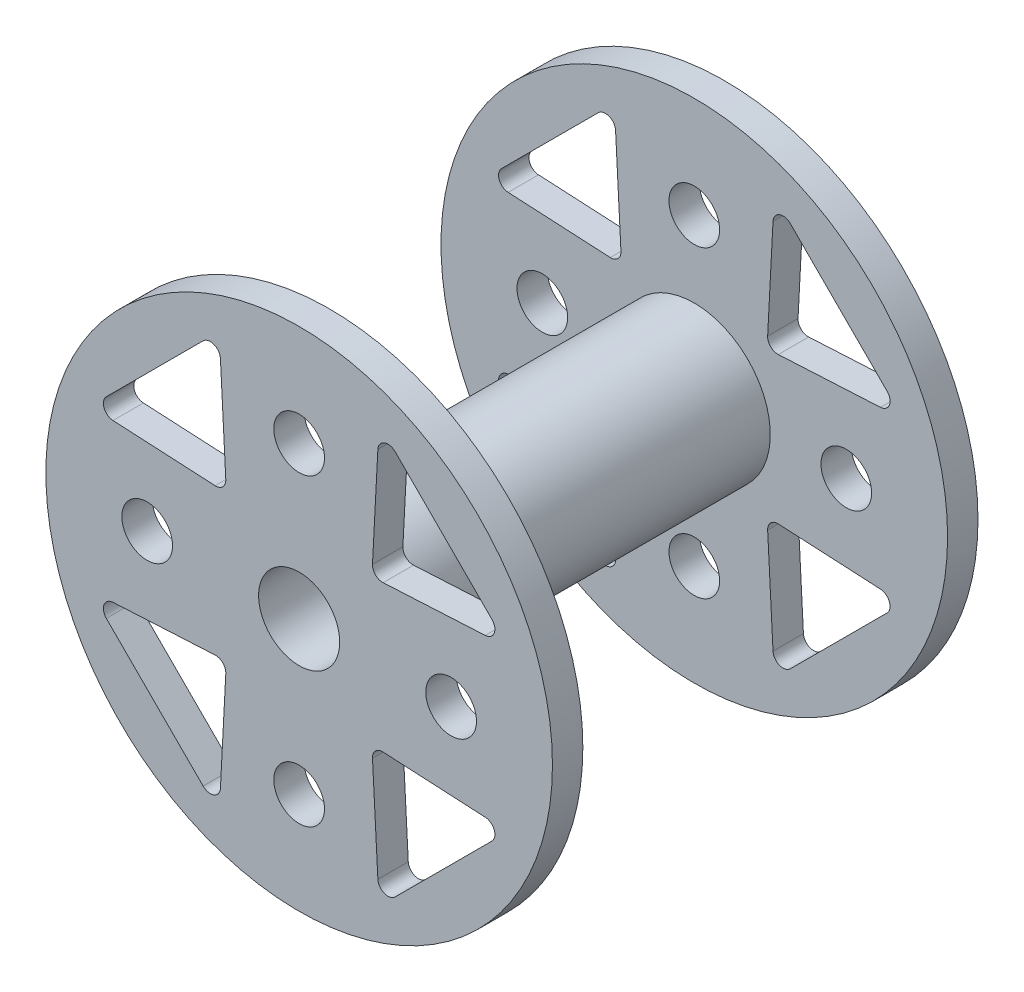
from build123d import *

# Parameters (mm, degrees)
CROQUIS1_R              = 7.5
CROQUIS1_R_2            = 4
SALIENTE_EXTRUIR1_DEPTH = 36
CROQUIS2_R              = 25
CROQUIS2_R_2            = 4
CROQUIS2_R_3            = 2.5
SALIENTE_EXTRUIR2_DEPTH = 3


with BuildPart() as part:
    # Croquis1 → Saliente-Extruir1 (new body)
    with BuildSketch(Plane.XY):
        Circle(CROQUIS1_R)
        Circle(CROQUIS1_R_2, mode=Mode.SUBTRACT)
    extrude(amount=SALIENTE_EXTRUIR1_DEPTH)

    # Croquis2 → Saliente-Extruir2 (add)
    with BuildSketch(Plane.XY.offset(36)):
        Circle(CROQUIS2_R)
        Circle(CROQUIS2_R_2, mode=Mode.SUBTRACT)
        with Locations((0, 15)):
            Circle(CROQUIS2_R_3, mode=Mode.SUBTRACT)
        with Locations((15, 0)):
            Circle(CROQUIS2_R_3, mode=Mode.SUBTRACT)
        with Locations((0, -15)):
            Circle(CROQUIS2_R_3, mode=Mode.SUBTRACT)
        with Locations((-15, 0)):
            Circle(CROQUIS2_R_3, mode=Mode.SUBTRACT)
        with BuildLine():
            Line((-19.027844597, 9.475344501), (-9.475344501, 19.027844597))
            ThreePointArc((-9.475344501, 19.027844597), (-8.409973952, 19.254358227), (-7.76961989, 18.373296649))
            Line((-7.76961989, 18.373296649), (-7.23892544, 8.290102103))
            ThreePointArc((-7.23892544, 8.290102103), (-7.530436489, 7.530436489), (-8.290102103, 7.23892544))
            Line((-8.290102103, 7.23892544), (-18.373296649, 7.76961989))
            ThreePointArc((-18.373296649, 7.76961989), (-19.254358227, 8.409973952), (-19.027844597, 9.475344501))
        make_face(mode=Mode.SUBTRACT)
        with BuildLine():
            Line((7.76961989, 18.373296649), (7.23892544, 8.290102103))
            ThreePointArc((7.23892544, 8.290102103), (7.530436489, 7.530436489), (8.290102103, 7.23892544))
            Line((8.290102103, 7.23892544), (18.373296649, 7.76961989))
            ThreePointArc((18.373296649, 7.76961989), (19.254358227, 8.409973952), (19.027844597, 9.475344501))
            Line((19.027844597, 9.475344501), (9.475344501, 19.027844597))
            ThreePointArc((9.475344501, 19.027844597), (8.409973952, 19.254358227), (7.76961989, 18.373296649))
        make_face(mode=Mode.SUBTRACT)
        with BuildLine():
            Line((18.373296649, -7.76961989), (8.290102103, -7.23892544))
            ThreePointArc((8.290102103, -7.23892544), (7.530436489, -7.530436489), (7.23892544, -8.290102103))
            Line((7.23892544, -8.290102103), (7.76961989, -18.373296649))
            ThreePointArc((7.76961989, -18.373296649), (8.409973952, -19.254358227), (9.475344501, -19.027844597))
            Line((9.475344501, -19.027844597), (19.027844597, -9.475344501))
            ThreePointArc((19.027844597, -9.475344501), (19.254358227, -8.409973952), (18.373296649, -7.76961989))
        make_face(mode=Mode.SUBTRACT)
        with BuildLine():
            Line((-7.76961989, -18.373296649), (-7.23892544, -8.290102103))
            ThreePointArc((-7.23892544, -8.290102103), (-7.530436489, -7.530436489), (-8.290102103, -7.23892544))
            Line((-8.290102103, -7.23892544), (-18.373296649, -7.76961989))
            ThreePointArc((-18.373296649, -7.76961989), (-19.254358227, -8.409973952), (-19.027844597, -9.475344501))
            Line((-19.027844597, -9.475344501), (-9.475344501, -19.027844597))
            ThreePointArc((-9.475344501, -19.027844597), (-8.409973952, -19.254358227), (-7.76961989, -18.373296649))
        make_face(mode=Mode.SUBTRACT)
    saliente_extruir2 = extrude(amount=SALIENTE_EXTRUIR2_DEPTH)

    # Simetría1: Saliente-Extruir2 across plane
    add(saliente_extruir2.mirror(Plane(origin=(0, 0, 18), x_dir=(1, 0, 0), z_dir=(0, 0, -1))))


solid = part.part
